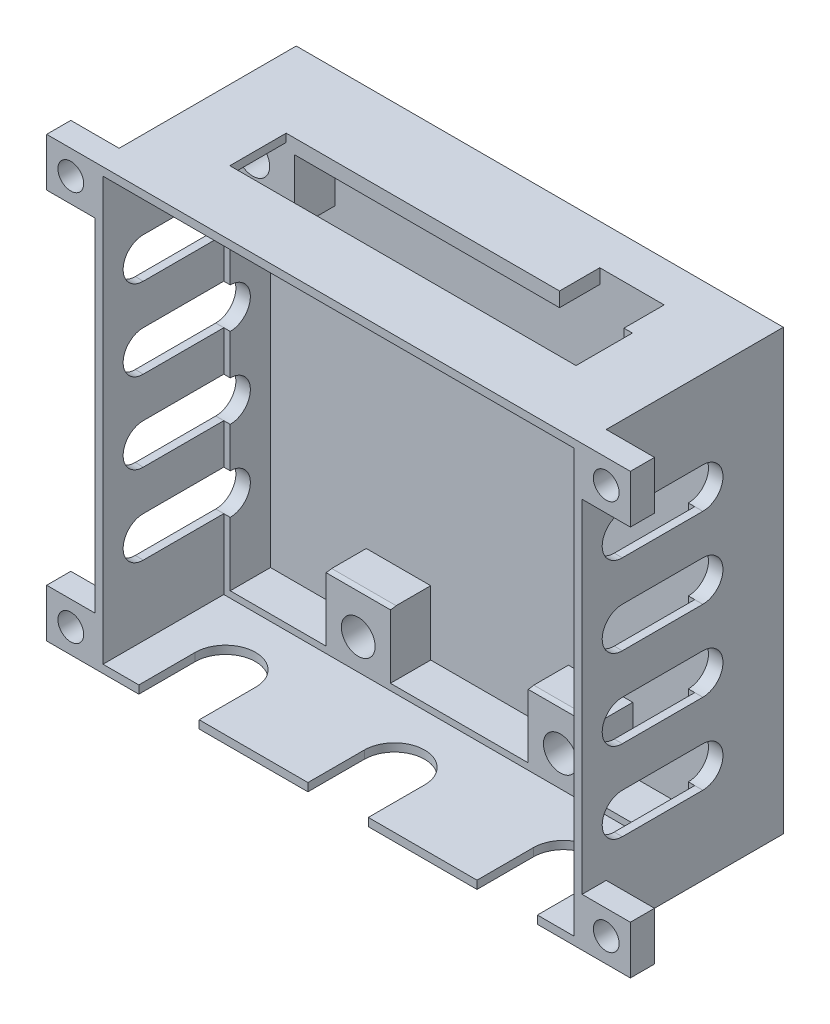
from build123d import *

# Parameters (mm, degrees)
CROQUIS1_W              = 60.5
CROQUIS1_H              = 54.5
SALIENTE_EXTRUIR1_DEPTH = 25
CROQUIS2_W              = 56.9
CROQUIS2_H              = 50.9
CORTAR_EXTRUIR1_DEPTH   = 15
CROQUIS3_R              = 2.1
CORTAR_EXTRUIR2_DEPTH   = 5
CORTAR_EXTRUIR3_DEPTH   = 5
CORTAR_EXTRUIR4_DEPTH   = 1.8
CORTAR_EXTRUIR6_START   = -1.8
CORTAR_EXTRUIR6_DEPTH   = 60.5
CROQUIS10_W             = 6
CROQUIS10_H             = 6
CROQUIS10_R             = 1.6
SALIENTE_EXTRUIR2_DEPTH = 3
CROQUIS11_W             = 58.5
CROQUIS11_H             = 52.5
CORTAR_EXTRUIR7_DEPTH   = 15


with BuildPart() as part:
    # Croquis1 → Saliente-Extruir1 (new body)
    with BuildSketch(Plane.XY):
        with Locations((-43.305557703, 3.094674556)):
            Rectangle(CROQUIS1_W, CROQUIS1_H)
    extrude(amount=SALIENTE_EXTRUIR1_DEPTH)

    # Croquis2 → Cortar-Extruir1 (cut)
    with BuildSketch(Plane.XY.offset(25)):
        with Locations((-43.305557703, 3.094674556)):
            Rectangle(CROQUIS2_W, CROQUIS2_H)
    extrude(amount=-CORTAR_EXTRUIR1_DEPTH, mode=Mode.SUBTRACT)

    # Croquis3 → Cortar-Extruir2 (cut)
    with BuildSketch(Plane.XY.offset(10)):
        with Locations((-68.955557703, 25.744674556)):
            Circle(CROQUIS3_R)
        with Locations((-55.855557703, -19.355325444)):
            Circle(CROQUIS3_R)
        with Locations((-30.755557703, -19.355325444)):
            Circle(CROQUIS3_R)
        with Locations((-17.655557703, 25.744674556)):
            Circle(CROQUIS3_R)
        Polygon((-71.755557703, 20.544674556), (-71.755557703, -22.355325444), (-59.855557703, -22.355325444), (-59.855557703, -14.355325444), (-51.855557703, -14.355325444), (-51.855557703, -22.355325444), (-34.755557703, -22.355325444), (-34.755557703, -14.355325444), (-26.755557703, -14.355325444), (-26.755557703, -22.355325444), (-14.855557703, -22.355325444), (-14.855557703, 20.544674556), (-22.855557703, 20.544674556), (-22.855557703, 28.544674556), (-63.755557703, 28.544674556), (-63.755557703, 20.544674556), align=None)
    extrude(amount=-CORTAR_EXTRUIR2_DEPTH, mode=Mode.SUBTRACT)

    # Croquis5 → Cortar-Extruir3 (cut)
    with BuildSketch(Plane(origin=(0, -22.355325444, 0), x_dir=(1, 0, 0), z_dir=(0, 1, 0))):
        with BuildLine():
            Line((-18.605557703, -18), (-18.605557703, -25))
            Line((-18.605557703, -25), (-26.105557703, -25))
            Line((-26.105557703, -25), (-26.105557703, -18))
            ThreePointArc((-26.105557703, -18), (-22.355557703, -14.25), (-18.605557703, -18))
        make_face()
        with BuildLine():
            Line((-39.605557703, -18), (-39.605557703, -25))
            Line((-39.605557703, -25), (-47.105557703, -25))
            Line((-47.105557703, -25), (-47.105557703, -18))
            ThreePointArc((-47.105557703, -18), (-43.355557703, -14.25), (-39.605557703, -18))
        make_face()
        with BuildLine():
            Line((-60.605557703, -18), (-60.605557703, -25))
            Line((-60.605557703, -25), (-68.105557703, -25))
            Line((-68.105557703, -25), (-68.105557703, -18))
            ThreePointArc((-68.105557703, -18), (-64.355557703, -14.25), (-60.605557703, -18))
        make_face()
    extrude(amount=-CORTAR_EXTRUIR3_DEPTH, mode=Mode.SUBTRACT)

    # Croquis6 → Cortar-Extruir4 (cut)
    with BuildSketch(Plane.XZ.offset(-28.544674556)):
        Polygon((-64.805557703, 17), (-21.805557703, 17), (-21.805557703, 10), (-22.855557703, 10), (-22.855557703, 5), (-30.855557703, 5), (-30.855557703, 10), (-64.805557703, 10), align=None)
    extrude(amount=-CORTAR_EXTRUIR4_DEPTH, mode=Mode.SUBTRACT)

    # Croquis9 → Cortar-Extruir6 (cut)
    with BuildSketch(Plane(origin=(-71.755557703, 0, 0), x_dir=(0, 0, -1), z_dir=(1, 0, 0)).offset(CORTAR_EXTRUIR6_START)):
        with BuildLine():
            Line((-10, 20.544674556), (-20, 20.544674556))
            ThreePointArc((-20, 20.544674556), (-22.5, 18.044674556), (-20, 15.544674556))
            Line((-20, 15.544674556), (-10, 15.544674556))
            ThreePointArc((-10, 15.544674556), (-7.5, 18.044674556), (-10, 20.544674556))
        make_face()
        with BuildLine():
            Line((-10, 10.544674556), (-20, 10.544674556))
            ThreePointArc((-20, 10.544674556), (-22.5, 8.044674556), (-20, 5.544674556))
            Line((-20, 5.544674556), (-10, 5.544674556))
            ThreePointArc((-10, 5.544674556), (-7.5, 8.044674556), (-10, 10.544674556))
        make_face()
        with BuildLine():
            Line((-10, 0.544674556), (-20, 0.544674556))
            ThreePointArc((-20, 0.544674556), (-22.5, -1.955325444), (-20, -4.455325444))
            Line((-20, -4.455325444), (-10, -4.455325444))
            ThreePointArc((-10, -4.455325444), (-7.5, -1.955325444), (-10, 0.544674556))
        make_face()
        with BuildLine():
            Line((-10, -9.455325444), (-20, -9.455325444))
            ThreePointArc((-20, -9.455325444), (-22.5, -11.955325444), (-20, -14.455325444))
            Line((-20, -14.455325444), (-10, -14.455325444))
            ThreePointArc((-10, -14.455325444), (-7.5, -11.955325444), (-10, -9.455325444))
        make_face()
    extrude(amount=CORTAR_EXTRUIR6_DEPTH, mode=Mode.SUBTRACT)

    # Croquis10 → Saliente-Extruir2 (add)
    with BuildSketch(Plane.XY.offset(25)):
        with Locations((-76.555557703, 27.344674556)):
            Rectangle(CROQUIS10_W, CROQUIS10_H)
        with Locations((-76.555557703, 27.344674556)):
            Circle(CROQUIS10_R, mode=Mode.SUBTRACT)
        with Locations((-10.055557703, 27.344674556)):
            Rectangle(CROQUIS10_W, CROQUIS10_H)
        with Locations((-10.055557703, 27.344674556)):
            Circle(CROQUIS10_R, mode=Mode.SUBTRACT)
        with Locations((-10.055557703, -21.155325444)):
            Rectangle(CROQUIS10_W, CROQUIS10_H)
        with Locations((-10.055557703, -21.155325444)):
            Circle(CROQUIS10_R, mode=Mode.SUBTRACT)
        with Locations((-76.555557703, -21.155325444)):
            Rectangle(CROQUIS10_W, CROQUIS10_H)
        with Locations((-76.555557703, -21.155325444)):
            Circle(CROQUIS10_R, mode=Mode.SUBTRACT)
    extrude(amount=-SALIENTE_EXTRUIR2_DEPTH)

    # Croquis11 → Cortar-Extruir7 (cut)
    with BuildSketch(Plane.XY.offset(25)):
        with Locations((-43.305557703, 3.094674556)):
            Rectangle(CROQUIS11_W, CROQUIS11_H)
    extrude(amount=-CORTAR_EXTRUIR7_DEPTH, mode=Mode.SUBTRACT)


solid = part.part
